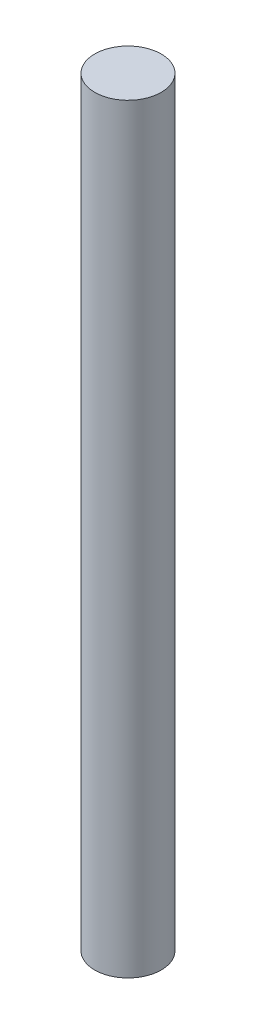
from build123d import *

# Parameters (mm, degrees)
SKETCH_1_R      = 3.5
EXTRUDE_1_DEPTH = 80


with BuildPart() as part:
    # Эскиз1 → Бобышка-Вытянуть1 (new body)
    with BuildSketch(Plane(origin=(0, 0, 0), x_dir=(1, 0, 0), z_dir=(0, 1, 0))):
        with Locations((-1.462025316, 1.528481013)):
            Circle(SKETCH_1_R)
    extrude(amount=EXTRUDE_1_DEPTH)


solid = part.part
